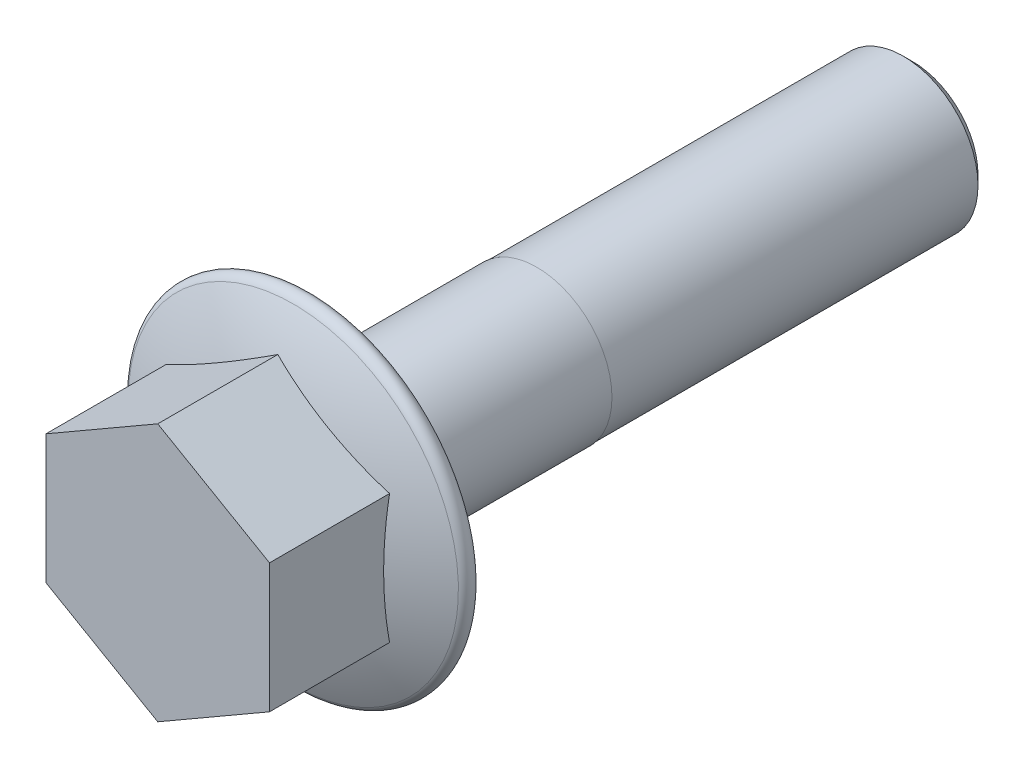
from build123d import *

# Parameters (mm, degrees)
HEAD_DEPTH     = 12.954
SHANK_SKETCH_R = 6.35
SHANK_DEPTH    = 50.8
THREAD_END_W   = 31.75
THREAD_END_H   = 0.05
CHAMFER1_SIZE  = 0.79375


with BuildPart() as part:
    # Head Sketch → Head (new body)
    with BuildSketch(Plane.XY):
        Polygon((0, 10.89586975), (9.4361, 5.447934875), (9.4361, -5.447934875), (0, -10.89586975), (-9.4361, -5.447934875), (-9.4361, 5.447934875), align=None)
    extrude(amount=HEAD_DEPTH)

    # Shank Sketch → Shank (add)
    with BuildSketch(Plane.XY):
        Circle(SHANK_SKETCH_R)
    extrude(amount=-SHANK_DEPTH)

    # Sketch3 → Flange (revolve)
    with BuildSketch(Plane(origin=(0, 0, 0), x_dir=(-1, 0, 0), z_dir=(0, 1, 0))):
        with BuildLine():
            Line((-13.589, 0), (0, 0))
            Line((0, 0), (0, 4.7625))
            ThreePointArc((0, 4.7625), (-7.158083275, 3.937386416), (-13.940711322, 1.505324458))
            ThreePointArc((-13.940711322, 1.505324458), (-14.361933143, 0.613158144), (-13.589, 0))
        make_face()
    revolve(axis=Axis((0, 0, 0), (0, 0, 1)))

    # Thread End → Thread Cut (revolve, cut)
    with BuildSketch(Plane(origin=(0, 0, 0), x_dir=(0, 0, -1), z_dir=(1, 0, 0))):
        with Locations((34.925, 6.325)):
            Rectangle(THREAD_END_W, THREAD_END_H)
    revolve(axis=Axis((0, 0, -21.551935625), (0, 0, -1)), mode=Mode.SUBTRACT)

    # Chamfer1
    chamfer1_edges = [part.edges().sort_by_distance(p)[0] for p in [
        (0, -6.3, -50.8),
    ]]
    chamfer(chamfer1_edges, length=CHAMFER1_SIZE)


solid = part.part
